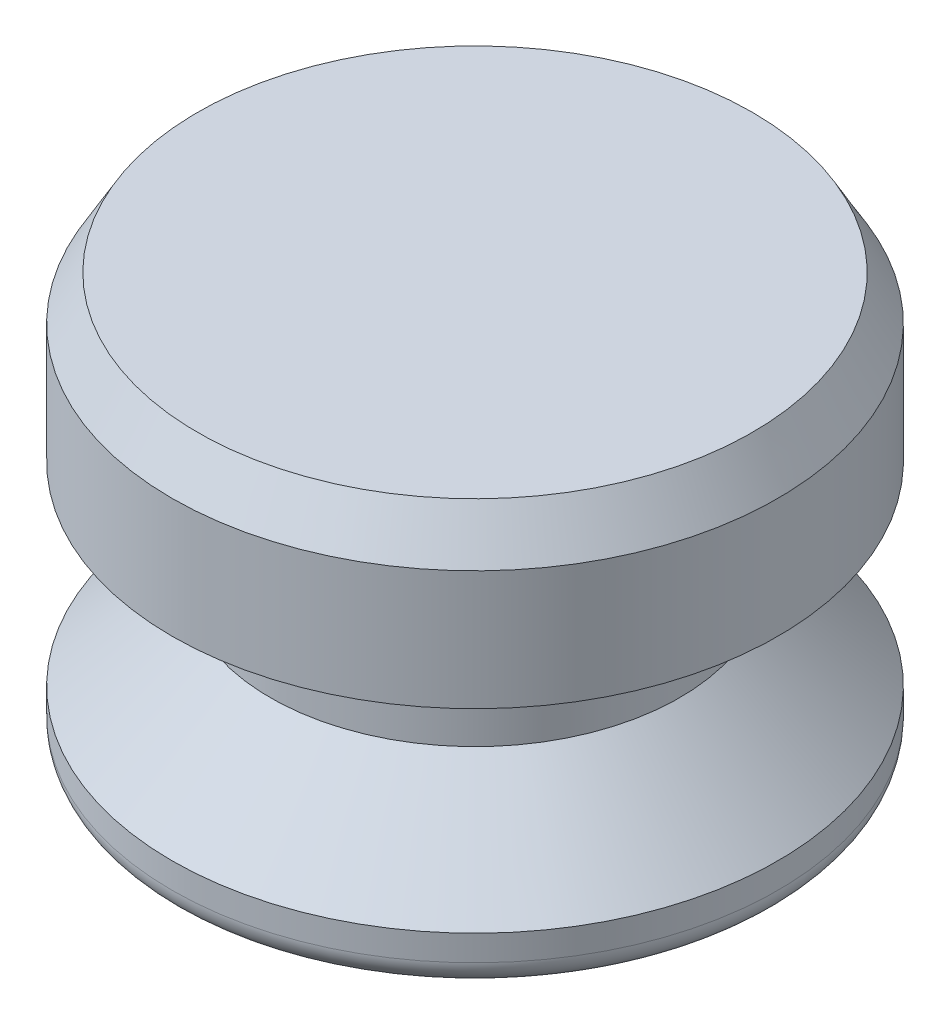
from build123d import *

# Parameters (mm, degrees)
FILLET1_R      = 0.79375
CHAMFER1_SIZE  = 0.79375
CHAMFER1_SIZE2 = 1.374815329


with BuildPart() as part:
    # Sketch1 → Revolve1 (revolve)
    with BuildSketch(Plane.XY):
        Polygon((0, 0), (-9.398, 0), (-9.398, 1.5875), (-6.35, 4.445), (-6.35, 7.62), (-9.398, 7.62), (-9.398, 12.7), (0, 12.7), align=None)
    revolve(axis=Axis((0, 0, 0), (0, 1, 0)))

    # Fillet1
    fillet1_edges = [part.edges().sort_by_distance(p)[0] for p in [
        (9.398, 0, 0),
    ]]
    fillet(fillet1_edges, radius=FILLET1_R)

    # Chamfer1
    chamfer1_edges = [part.edges().sort_by_distance(p)[0] for p in [
        (9.398, 12.7, 0),
    ]]
    chamfer1_side = [part.faces().sort_by_distance(p)[0] for p in [
        (0, 12.7, 0),
    ]]
    chamfer(chamfer1_edges, length=CHAMFER1_SIZE, length2=CHAMFER1_SIZE2, reference=chamfer1_side[0])


solid = part.part
